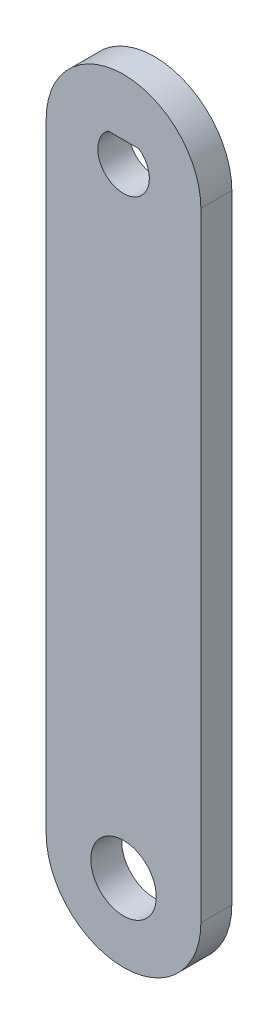
from build123d import *

# Parameters (mm, degrees)
SALIENTE_EXTRUIR1_DEPTH      = 1.5
SALIENTE_EXTRUIR1_DEPTH_BACK = 1.5
CROQUIS1_R                   = 3.175


with BuildPart() as part:
    # Croquis1 → Saliente-Extruir1 (new, two sides: drawn at the far end of the back side and taken through both)
    with BuildSketch(Plane.XY.offset(-SALIENTE_EXTRUIR1_DEPTH_BACK)):
        with BuildLine():
            Line((7.5, 0), (7.5, -60))
            ThreePointArc((7.5, -60), (0, -67.5), (-7.5, -60))
            Line((-7.5, -60), (-7.5, 0))
            ThreePointArc((-7.5, 0), (0, 7.5), (7.5, 0))
        make_face()
        with Locations((0, -60)):
            Circle(CROQUIS1_R, mode=Mode.SUBTRACT)
        with BuildLine():
            Line((-1.5, 2), (1.5, 2))
            ThreePointArc((1.5, 2), (0, -2.5), (-1.5, 2))
        make_face(mode=Mode.SUBTRACT)
    extrude(amount=SALIENTE_EXTRUIR1_DEPTH + SALIENTE_EXTRUIR1_DEPTH_BACK)


solid = part.part
